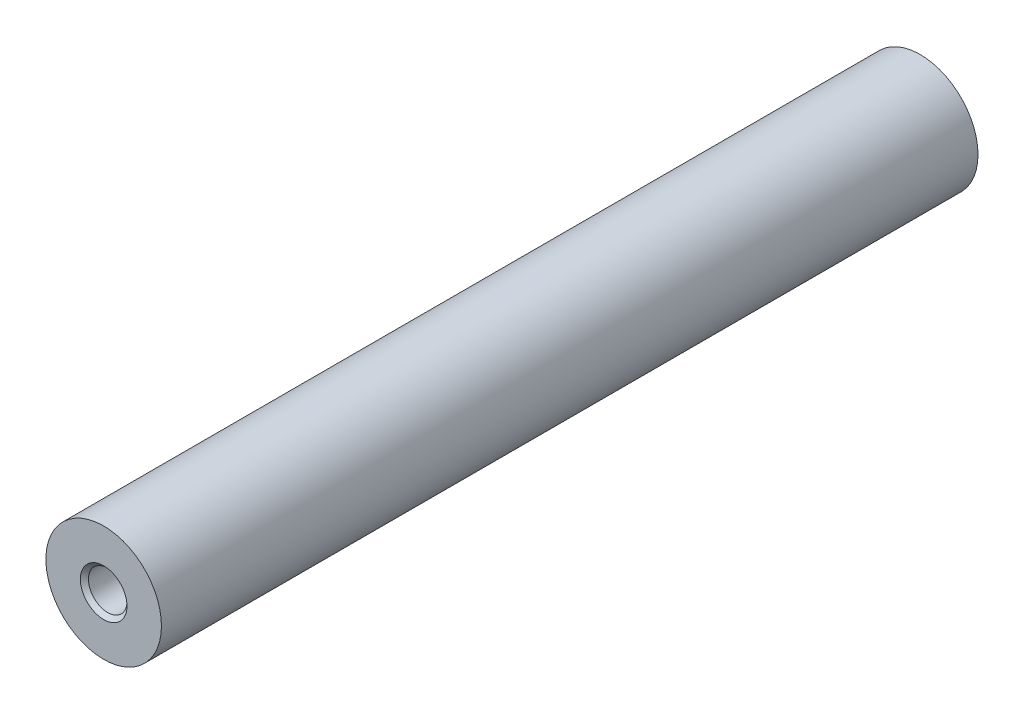
from build123d import *

# Parameters (mm, degrees)
SKETCH1_R           = 7.5
BOSS_EXTRUDE1_DEPTH = 53


with BuildPart() as part:
    # Sketch1 → Boss-Extrude1 (new body, symmetric)
    with BuildSketch(Plane.XY):
        Circle(SKETCH1_R)
    extrude(amount=BOSS_EXTRUDE1_DEPTH, both=True)

    # Sketch3 → M6x1.0 Tapped Hole1 (revolve, cut)
    with BuildSketch(Plane(origin=(0, 0, 53), x_dir=(0, -1, 0), z_dir=(1, 0, 0))):
        Polygon((0, 0), (0, 16.502151548), (2.5, 15), (2.5, 0.525), (3.025, 0), align=None)
    m6x1_0_tapped_hole1 = revolve(axis=Axis((0, 0, 59.35), (0, 0, -1)), mode=Mode.SUBTRACT)

    # Mirror1: M6x1.0 Tapped Hole1 across plane
    add(m6x1_0_tapped_hole1.mirror(Plane.XY), mode=Mode.SUBTRACT)


solid = part.part
